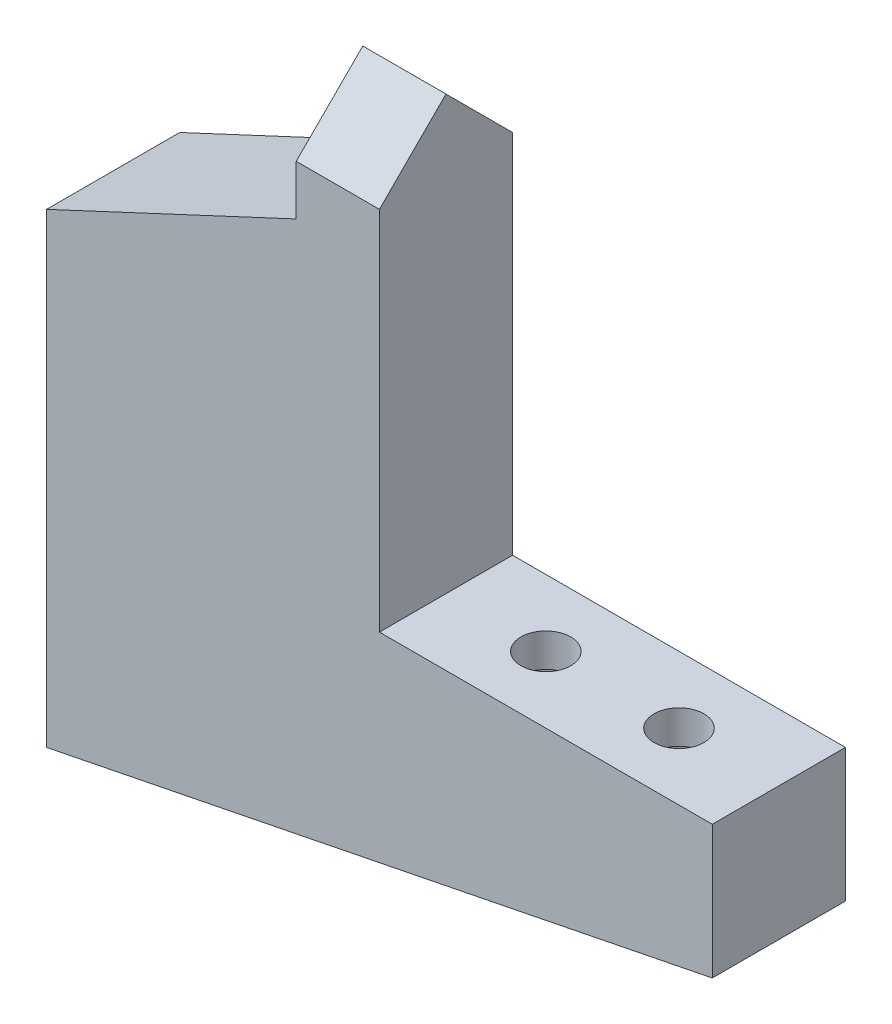
from build123d import *

# Parameters (mm, degrees)
BOSS_EXTRUDE1_DEPTH       = 8
CUT_EXTRUDE1_DEPTH        = 8
SKETCH7_R                 = 1.5
CUT_EXTRUDE4_DEPTH        = 2
SKETCH9_R                 = 2.5
CUT_EXTRUDE5_DEPTH        = 15
CUT_EXTRUDE2_DEPTH        = 21
CUT_EXTRUDE3_DEPTH        = 21
M2X0_4_TAPPED_HOLE1_D     = 1.6
M2X0_4_TAPPED_HOLE1_DEPTH = 8
M2X0_4_TAPPED_HOLE1_TIP   = 0.480688495


with BuildPart() as part:
    # Sketch1 → Boss-Extrude1 (new body)
    with BuildSketch(Plane.XY):
        Polygon((0, 0), (0, 42), (20, 42), (20, 16), (40, 16), (40, 8), align=None)
    extrude(amount=BOSS_EXTRUDE1_DEPTH)

    # Sketch2 → Cut-Extrude1 (cut)
    with BuildSketch(Plane.XY.offset(8)):
        Polygon((15, 42), (15, 35), (0, 28), (0, 42), align=None)
    extrude(amount=-CUT_EXTRUDE1_DEPTH, mode=Mode.SUBTRACT)

    # Sketch7 → Cut-Extrude4 (cut)
    with BuildSketch(Plane(origin=(0, 16, 0), x_dir=(1, 0, 0), z_dir=(0, 1, 0))):
        with Locations((34, -4)):
            Circle(SKETCH7_R)
        with Locations((26, -4)):
            Circle(SKETCH7_R)
    extrude(amount=-CUT_EXTRUDE4_DEPTH, mode=Mode.SUBTRACT)

    # Sketch9 → Cut-Extrude5 (cut, through all)
    with BuildSketch(Plane(origin=(0, 14, 0), x_dir=(1, 0, 0), z_dir=(0, 1, 0))):
        with Locations((34, -4)):
            Circle(SKETCH9_R)
        with Locations((26, -4)):
            Circle(SKETCH9_R)
    extrude(amount=-CUT_EXTRUDE5_DEPTH, mode=Mode.SUBTRACT)

    # Sketch5 → Cut-Extrude2 (cut, through all)
    with BuildSketch(Plane(origin=(20, 0, 0), x_dir=(0, 0, -1), z_dir=(1, 0, 0))):
        Polygon((-8, 42), (-4, 42), (-8, 38), align=None)
    extrude(amount=-CUT_EXTRUDE2_DEPTH, mode=Mode.SUBTRACT)

    # Sketch6 → Cut-Extrude3 (cut, through all)
    with BuildSketch(Plane(origin=(20, 0, 0), x_dir=(0, 0, -1), z_dir=(1, 0, 0))):
        Polygon((0, 42), (-4, 42), (0, 38), align=None)
    extrude(amount=-CUT_EXTRUDE3_DEPTH, mode=Mode.SUBTRACT)

    # M2x0.4 Tapped Hole1
    with Locations(Plane(origin=(0, 24, 4), x_dir=(0, 0, -1), z_dir=(-1, 0, 0))):
        with Locations((0, 0), (0, 8), (0, 16)):
            Hole(M2X0_4_TAPPED_HOLE1_D / 2, depth=M2X0_4_TAPPED_HOLE1_DEPTH)
            with Locations((0, 0, -(M2X0_4_TAPPED_HOLE1_DEPTH + M2X0_4_TAPPED_HOLE1_TIP / 2))):  # 118° drill point
                Cone(0, M2X0_4_TAPPED_HOLE1_D / 2, M2X0_4_TAPPED_HOLE1_TIP, mode=Mode.SUBTRACT)


solid = part.part
